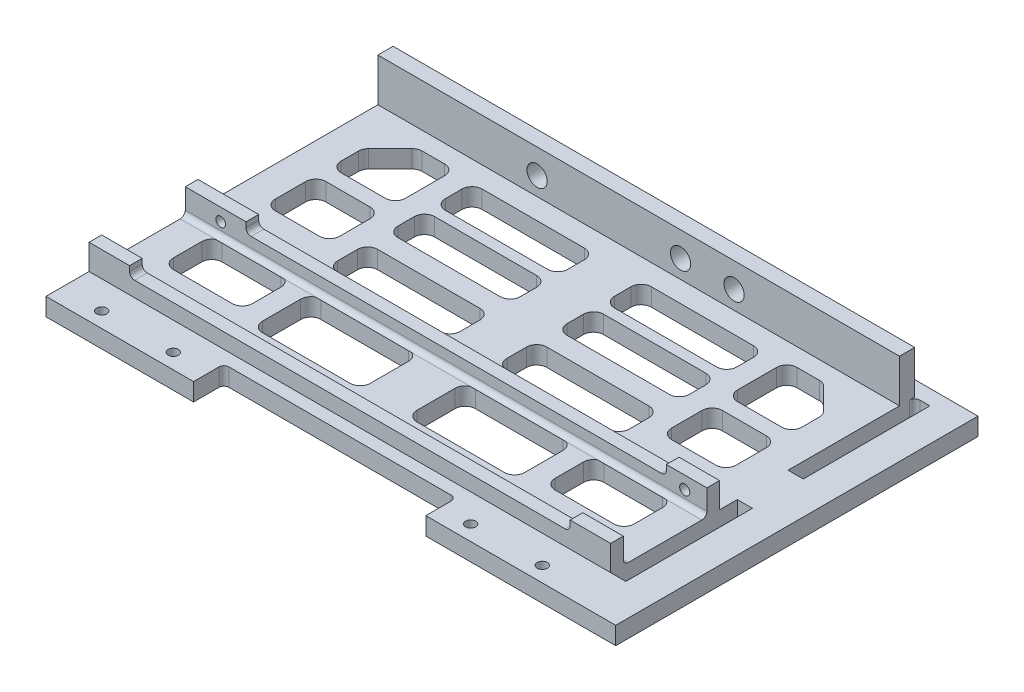
from build123d import *

# Parameters (mm, degrees)
SKETCH1_W            = 103
SKETCH1_H            = 62.54
BOSS_EXTRUDE1_DEPTH  = 3.5
SKETCH2_W            = 103
SKETCH2_H            = 3.5
BOSS_EXTRUDE2_DEPTH  = 3
SKETCH8_W            = 103
SKETCH8_H            = 2.5
BOSS_EXTRUDE6_DEPTH  = 3
SKETCH9_W            = 8
SKETCH9_H            = 2.5
BOSS_EXTRUDE7_DEPTH  = 2
SKETCH11_R           = 1
CUT_EXTRUDE3_DEPTH   = 22
FILLET4_R            = 1
SKETCH12_W           = 12
SKETCH12_H           = 2.5
BOSS_EXTRUDE8_DEPTH  = 2
FILLET5_R            = 1
SKETCH13_R           = 0.95132711
CUT_EXTRUDE4_DEPTH   = 12
FILLET6_R            = 1
SKETCH14_W           = 103
SKETCH14_H           = 2.5
BOSS_EXTRUDE9_DEPTH  = 3
SKETCH15_W           = 8
SKETCH15_H           = 2.5
BOSS_EXTRUDE10_DEPTH = 2
FILLET7_R            = 1
CUT_EXTRUDE6_DEPTH   = 5
SKETCH18_W           = 103
SKETCH18_H           = 3
BOSS_EXTRUDE11_DEPTH = 8.5
SKETCH20_W           = 29.14
SKETCH20_H           = 3.5
SKETCH20_W_2         = 28
BOSS_EXTRUDE12_DEPTH = 6
FILLET8_R            = 1
SKETCH21_R           = 1
CUT_EXTRUDE7_DEPTH   = 6
SKETCH22_W           = 71.54
SKETCH22_H           = 3.5
BOSS_EXTRUDE13_DEPTH = 6.5
SKETCH23_W           = 3
SKETCH23_H           = 60.04
CUT_EXTRUDE8_DEPTH   = 10
SKETCH25_R           = 2
CUT_EXTRUDE9_DEPTH   = 10
SKETCH26_W           = 3
SKETCH26_H           = 10.04
BOSS_EXTRUDE14_DEPTH = 3.5
SKETCH27_W           = 71.54
SKETCH27_H           = 3.5
BOSS_EXTRUDE15_DEPTH = 3
FILLET9_R            = 1


with BuildPart() as part:
    # Sketch1 → Boss-Extrude1 (new body)
    with BuildSketch(Plane(origin=(0, 0, 0), x_dir=(1, 0, 0), z_dir=(0, 1, 0))):
        Rectangle(SKETCH1_W, SKETCH1_H)
    extrude(amount=BOSS_EXTRUDE1_DEPTH)

    # Sketch2 → Boss-Extrude2 (add)
    with BuildSketch(Plane(origin=(0, 0, -31.27), x_dir=(-1, 0, 0), z_dir=(0, 0, -1))):
        with Locations((0, 1.75)):
            Rectangle(SKETCH2_W, SKETCH2_H)
    extrude(amount=BOSS_EXTRUDE2_DEPTH)

    # Sketch8 → Boss-Extrude6 (add)
    with BuildSketch(Plane(origin=(0, 3.5, 0), x_dir=(1, 0, 0), z_dir=(0, 1, 0))):
        with Locations((0, -8.52)):
            Rectangle(SKETCH8_W, SKETCH8_H)
    extrude(amount=BOSS_EXTRUDE6_DEPTH)

    # Sketch9 → Boss-Extrude7 (add)
    with BuildSketch(Plane(origin=(0, 6.5, 0), x_dir=(1, 0, 0), z_dir=(0, 1, 0))):
        with Locations((47.5, -8.52)):
            Rectangle(SKETCH9_W, SKETCH9_H)
    extrude(amount=BOSS_EXTRUDE7_DEPTH)

    # Sketch11 → Cut-Extrude3 (cut)
    with BuildSketch(Plane.XY.offset(9.77)):
        with Locations((47.13, 6)):
            Circle(SKETCH11_R)
    extrude(amount=-CUT_EXTRUDE3_DEPTH, mode=Mode.SUBTRACT)

    # Fillet4
    fillet4_edges = [part.edges().sort_by_distance(p)[0] for p in [
        (0, 3.5, 9.77),
    ]]
    fillet(fillet4_edges, radius=FILLET4_R)

    # Sketch12 → Boss-Extrude8 (add)
    with BuildSketch(Plane(origin=(0, 6.5, 0), x_dir=(1, 0, 0), z_dir=(0, 1, 0))):
        with Locations((-45.5, -8.52)):
            Rectangle(SKETCH12_W, SKETCH12_H)
    extrude(amount=BOSS_EXTRUDE8_DEPTH)

    # Fillet5
    fillet5_edges = [part.edges().sort_by_distance(p)[0] for p in [
        (-39.5, 6.5, 8.52),
    ]]
    fillet(fillet5_edges, radius=FILLET5_R)

    # Sketch13 → Cut-Extrude4 (cut)
    with BuildSketch(Plane.XY.offset(9.77)):
        with Locations((-44.5, 6)):
            Circle(SKETCH13_R)
    extrude(amount=-CUT_EXTRUDE4_DEPTH, mode=Mode.SUBTRACT)

    # Fillet6
    fillet6_edges = [part.edges().sort_by_distance(p)[0] for p in [
        (43.5, 6.5, 8.52),
    ]]
    fillet(fillet6_edges, radius=FILLET6_R)

    # Sketch14 → Boss-Extrude9 (add)
    with BuildSketch(Plane(origin=(0, 3.5, 0), x_dir=(1, 0, 0), z_dir=(0, 1, 0))):
        with Locations((0, -27.52)):
            Rectangle(SKETCH14_W, SKETCH14_H)
    extrude(amount=BOSS_EXTRUDE9_DEPTH)

    # Sketch15 → Boss-Extrude10 (add)
    with BuildSketch(Plane(origin=(0, 6.5, 0), x_dir=(1, 0, 0), z_dir=(0, 1, 0))):
        with Locations((47.5, -27.52)):
            Rectangle(SKETCH15_W, SKETCH15_H)
        with Locations((-47.5, -27.52)):
            Rectangle(SKETCH15_W, SKETCH15_H)
    extrude(amount=BOSS_EXTRUDE10_DEPTH)

    # Fillet7
    fillet7_edges = [part.edges().sort_by_distance(p)[0] for p in [
        (0, 3.5, 26.27),
        (43.5, 6.5, 27.52),
        (-43.5, 6.5, 27.52),
    ]]
    fillet(fillet7_edges, radius=FILLET7_R)

    # Sketch17 → Cut-Extrude6 (cut)
    with BuildSketch(Plane(origin=(0, 3.5, 0), x_dir=(1, 0, 0), z_dir=(0, 1, 0))):
        with BuildLine():
            Line((43.5, -20.117308559), (31.88534696, -20.117308559))
            ThreePointArc((31.88534696, -20.117308559), (30.471133397, -19.531522121), (29.88534696, -18.117308559))
            Line((29.88534696, -18.117308559), (29.88534696, -12.508106744))
            ThreePointArc((29.88534696, -12.508106744), (30.471133397, -11.093893181), (31.88534696, -10.508106744))
            Line((31.88534696, -10.508106744), (43.5, -10.508106744))
            ThreePointArc((43.5, -10.508106744), (44.914213562, -11.093893181), (45.5, -12.508106744))
            Line((45.5, -12.508106744), (45.5, -18.117308559))
            ThreePointArc((45.5, -18.117308559), (44.914213562, -19.531522121), (43.5, -20.117308559))
        make_face()
        with BuildLine():
            Line((25.88534696, -20.121075172), (25.88534696, -12.585776052))
            ThreePointArc((25.88534696, -12.585776052), (25.299560522, -11.171562489), (23.88534696, -10.585776052))
            Line((23.88534696, -10.585776052), (6.608652469, -10.585776052))
            ThreePointArc((6.608652469, -10.585776052), (5.194438907, -11.171562489), (4.608652469, -12.585776052))
            Line((4.608652469, -12.585776052), (4.608652469, -20.121075172))
            ThreePointArc((4.608652469, -20.121075172), (5.194438907, -21.535288735), (6.608652469, -22.121075172))
            Line((6.608652469, -22.121075172), (23.88534696, -22.121075172))
            ThreePointArc((23.88534696, -22.121075172), (25.299560522, -21.535288735), (25.88534696, -20.121075172))
        make_face()
        with BuildLine():
            Line((44.914213562, 19.849036172), (40.619219164, 24.14403057))
            ThreePointArc((40.619219164, 24.14403057), (39.970372466, 24.577576073), (39.205005602, 24.729817008))
            Line((39.205005602, 24.729817008), (34.780809577, 24.729817008))
            ThreePointArc((34.780809577, 24.729817008), (33.366596015, 24.14403057), (32.780809577, 22.729817008))
            Line((32.780809577, 22.729817008), (32.780809577, 15.003047088))
            ThreePointArc((32.780809577, 15.003047088), (33.366596015, 13.588833526), (34.780809577, 13.003047088))
            Line((34.780809577, 13.003047088), (43.5, 13.003047088))
            ThreePointArc((43.5, 13.003047088), (44.914213562, 13.588833526), (45.5, 15.003047088))
            Line((45.5, 15.003047088), (45.5, 18.43482261))
            ThreePointArc((45.5, 18.43482261), (45.347759065, 19.200189474), (44.914213562, 19.849036172))
        make_face()
        with BuildLine():
            Line((43.5, 10.003047088), (34.780809577, 10.003047088))
            ThreePointArc((34.780809577, 10.003047088), (33.366596015, 9.417260651), (32.780809577, 8.003047088))
            Line((32.780809577, 8.003047088), (32.780809577, 2))
            ThreePointArc((32.780809577, 2), (33.366596015, 0.585786438), (34.780809577, 0))
            Line((34.780809577, 0), (43.5, 0))
            ThreePointArc((43.5, 0), (44.914213562, 0.585786438), (45.5, 2))
            Line((45.5, 2), (45.5, 8.003047088))
            ThreePointArc((45.5, 8.003047088), (44.914213562, 9.417260651), (43.5, 10.003047088))
        make_face()
        with BuildLine():
            Line((28.780809577, -2.383609448), (28.780809577, 1.515202186))
            ThreePointArc((28.780809577, 1.515202186), (28.19502314, 2.929415749), (26.780809577, 3.515202186))
            Line((26.780809577, 3.515202186), (6.608652469, 3.515202186))
            ThreePointArc((6.608652469, 3.515202186), (5.194438907, 2.929415749), (4.608652469, 1.515202186))
            Line((4.608652469, 1.515202186), (4.608652469, -2.383609448))
            ThreePointArc((4.608652469, -2.383609448), (5.194438907, -3.79782301), (6.608652469, -4.383609448))
            Line((6.608652469, -4.383609448), (26.780809577, -4.383609448))
            ThreePointArc((26.780809577, -4.383609448), (28.19502314, -3.79782301), (28.780809577, -2.383609448))
        make_face()
        with BuildLine():
            Line((28.780809577, 9.515202186), (28.780809577, 12.740009568))
            ThreePointArc((28.780809577, 12.740009568), (28.19502314, 14.15422313), (26.780809577, 14.740009568))
            Line((26.780809577, 14.740009568), (6.608652469, 14.740009568))
            ThreePointArc((6.608652469, 14.740009568), (5.194438907, 14.15422313), (4.608652469, 12.740009568))
            Line((4.608652469, 12.740009568), (4.608652469, 9.515202186))
            ThreePointArc((4.608652469, 9.515202186), (5.194438907, 8.100988624), (6.608652469, 7.515202186))
            Line((6.608652469, 7.515202186), (26.780809577, 7.515202186))
            ThreePointArc((26.780809577, 7.515202186), (28.19502314, 8.100988624), (28.780809577, 9.515202186))
        make_face()
        with BuildLine():
            Line((26.780809577, 16.871271727), (6.608652469, 16.871271727))
            ThreePointArc((6.608652469, 16.871271727), (5.194438907, 17.457058165), (4.608652469, 18.871271727))
            Line((4.608652469, 18.871271727), (4.608652469, 22.14403057))
            ThreePointArc((4.608652469, 22.14403057), (5.194438907, 23.558244133), (6.608652469, 24.14403057))
            Line((6.608652469, 24.14403057), (26.780809577, 24.14403057))
            ThreePointArc((26.780809577, 24.14403057), (28.19502314, 23.558244133), (28.780809577, 22.14403057))
            Line((28.780809577, 22.14403057), (28.780809577, 18.871271727))
            ThreePointArc((28.780809577, 18.871271727), (28.19502314, 17.457058165), (26.780809577, 16.871271727))
        make_face()
    cut_extrude6 = extrude(amount=-CUT_EXTRUDE6_DEPTH, mode=Mode.SUBTRACT)

    # Mirror4: Cut-Extrude6 across plane
    add(cut_extrude6.mirror(Plane(origin=(0, 0, 0), x_dir=(0, 0, 1), z_dir=(1, 0, 0))), mode=Mode.SUBTRACT)

    # Sketch18 → Boss-Extrude11 (add)
    with BuildSketch(Plane(origin=(0, 3.5, 0), x_dir=(1, 0, 0), z_dir=(0, 1, 0))):
        with Locations((0, 29.77)):
            Rectangle(SKETCH18_W, SKETCH18_H)
    extrude(amount=BOSS_EXTRUDE11_DEPTH)

    # Sketch20 → Boss-Extrude12 (add)
    with BuildSketch(Plane.XY.offset(31.27)):
        with Locations((-36.93, 1.75)):
            Rectangle(SKETCH20_W, SKETCH20_H)
        with Locations((37.5, 1.75)):
            Rectangle(SKETCH20_W_2, SKETCH20_H)
    extrude(amount=BOSS_EXTRUDE12_DEPTH)

    # Fillet8
    fillet8_edges = [part.edges().sort_by_distance(p)[0] for p in [
        (-22.36, 1.75, 31.27),
        (23.5, 1.75, 31.27),
    ]]
    fillet(fillet8_edges, radius=FILLET8_R)

    # Sketch21 → Cut-Extrude7 (cut)
    with BuildSketch(Plane.XZ):
        with Locations((-43.5, 34.27)):
            Circle(SKETCH21_R)
        with Locations((-29.36, 34.27)):
            Circle(SKETCH21_R)
    cut_extrude7 = extrude(amount=-CUT_EXTRUDE7_DEPTH, mode=Mode.SUBTRACT)

    # Mirror5: Cut-Extrude7 across plane
    add(cut_extrude7.mirror(Plane(origin=(0, 0, 0), x_dir=(0, 0, 1), z_dir=(1, 0, 0))), mode=Mode.SUBTRACT)

    # Sketch22 → Boss-Extrude13 (add)
    with BuildSketch(Plane(origin=(51.5, 0, 0), x_dir=(0, 0, -1), z_dir=(1, 0, 0))):
        with Locations((-1.5, 1.75)):
            Rectangle(SKETCH22_W, SKETCH22_H)
    extrude(amount=BOSS_EXTRUDE13_DEPTH)

    # Sketch23 → Cut-Extrude8 (cut)
    with BuildSketch(Plane(origin=(0, 3.5, 0), x_dir=(1, 0, 0), z_dir=(0, 1, 0))):
        with Locations((53, 1.25)):
            Rectangle(SKETCH23_W, SKETCH23_H)
    extrude(amount=-CUT_EXTRUDE8_DEPTH, mode=Mode.SUBTRACT)

    # Sketch25 → Cut-Extrude9 (cut)
    with BuildSketch(Plane.XY.offset(-28.27)):
        with Locations((18.84, 7.1)):
            Circle(SKETCH25_R)
        with Locations((8.27, 7.1)):
            Circle(SKETCH25_R)
        with Locations((-20.06, 7.1)):
            Circle(SKETCH25_R)
    extrude(amount=-CUT_EXTRUDE9_DEPTH, mode=Mode.SUBTRACT)

    # Sketch26 → Boss-Extrude14 (add)
    with BuildSketch(Plane.XZ):
        with Locations((53, -1.25)):
            Rectangle(SKETCH26_W, SKETCH26_H)
    extrude(amount=-BOSS_EXTRUDE14_DEPTH)

    # Sketch27 → Boss-Extrude15 (add)
    with BuildSketch(Plane(origin=(58, 0, 0), x_dir=(0, 0, -1), z_dir=(1, 0, 0))):
        with Locations((-1.5, 1.75)):
            Rectangle(SKETCH27_W, SKETCH27_H)
    extrude(amount=BOSS_EXTRUDE15_DEPTH)

    # Fillet9
    fillet9_edges = [part.edges().sort_by_distance(p)[0] for p in [
        (51.5, 1.75, -31.27),
    ]]
    fillet(fillet9_edges, radius=FILLET9_R)


solid = part.part
